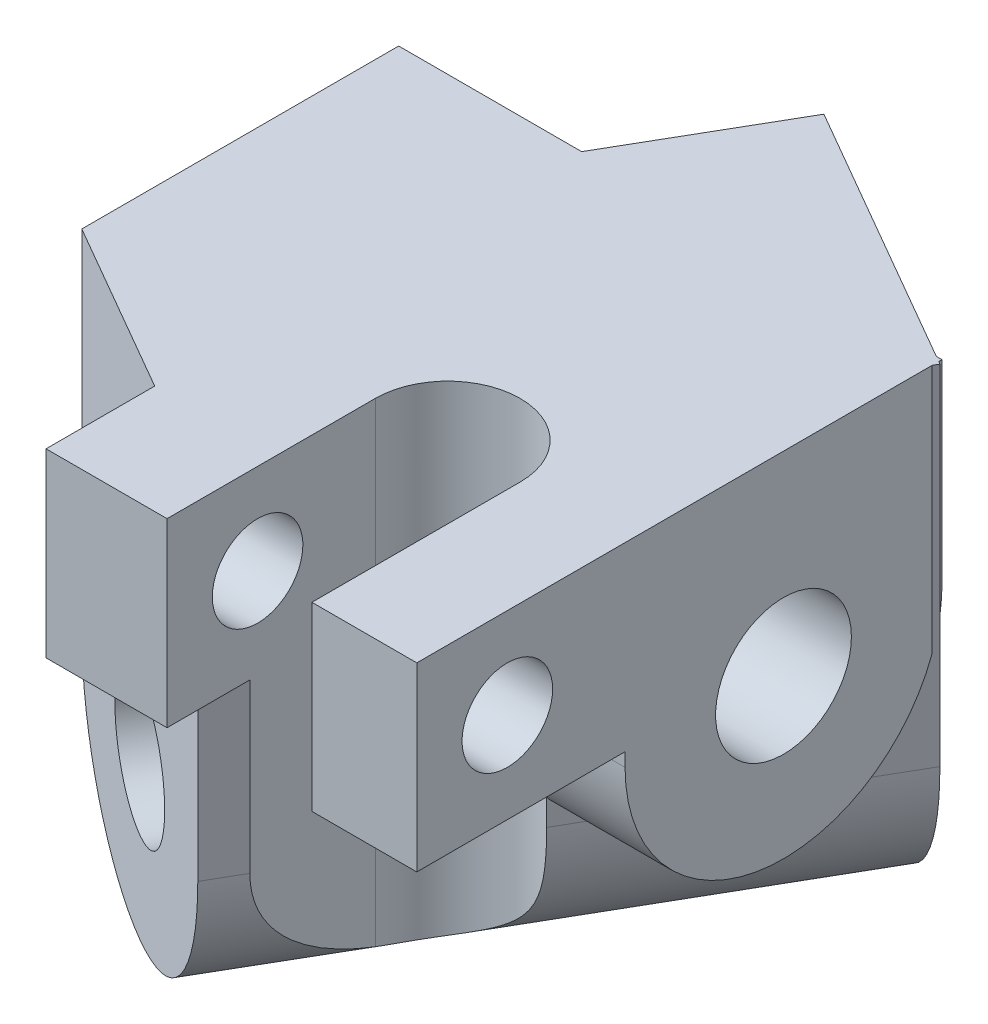
from build123d import *

# Parameters (mm, degrees)
SKETCH1_R           = 3.75
BOSS_EXTRUDE1_DEPTH = 30
SKETCH2_R           = 3.75
BOSS_EXTRUDE2_DEPTH = 30
CUT_EXTRUDE1_DEPTH  = 29.0000001
SKETCH4_W           = 5.792740578
SKETCH4_H           = 11.5
BOSS_EXTRUDE3_DEPTH = 10
BOSS_EXTRUDE4_DEPTH = 10
SKETCH5_R           = 2.5
CUT_EXTRUDE2_DEPTH  = 31.0000001
SKETCH7_R           = 3.75
CUT_EXTRUDE3_DEPTH  = 31.155444666
SKETCH8_R           = 3.75
CUT_EXTRUDE4_DEPTH  = 38.57772242


with BuildPart() as part:
    # Sketch1 → Boss-Extrude1 (new body)
    with BuildSketch(Plane(origin=(0, 0, 0), x_dir=(0, 0, -1), z_dir=(1, 0, 0))):
        with BuildLine():
            Line((-8.75, 0), (8.75, 0))
            Line((8.75, 0), (8.75, 10.75))
            ThreePointArc((8.75, 10.75), (0, 19.5), (-8.75, 10.75))
            Line((-8.75, 10.75), (-8.75, 0))
        make_face()
        with Locations((0, 10.75)):
            Circle(SKETCH1_R, mode=Mode.SUBTRACT)
    extrude(amount=BOSS_EXTRUDE1_DEPTH)

    # Sketch2 → Boss-Extrude2 (add)
    with BuildSketch(Plane(origin=(-3.788861142, 0, 6.5625), x_dir=(-0.866025404, 0, -0.5), z_dir=(0.5, 0, -0.866025404))):
        with BuildLine():
            Line((-4.375, 0), (-4.375, 19.25))
            ThreePointArc((-4.375, 19.25), (-13.125, 28), (-21.875, 19.25))
            Line((-21.875, 19.25), (-21.875, 0))
            Line((-21.875, 0), (-4.375, 0))
        make_face()
        with Locations((-13.125, 19.25)):
            Circle(SKETCH2_R, mode=Mode.SUBTRACT)
    extrude(amount=BOSS_EXTRUDE2_DEPTH)

    # Sketch3 → Cut-Extrude1 (cut, through all)
    with BuildSketch(Plane.XZ):
        with BuildLine():
            Line((24.207259422, 8.75), (24.207259422, 15.67820323))
            Line((24.207259422, 15.67820323), (16.207259422, 15.67820323))
            Line((16.207259422, 15.67820323), (16.207259422, 8.75))
            ThreePointArc((16.207259422, 8.75), (20.207259422, 4.75), (24.207259422, 8.75))
        make_face()
    extrude(amount=-CUT_EXTRUDE1_DEPTH, mode=Mode.SUBTRACT)

    # Sketch4 → Boss-Extrude3 (add)
    with BuildSketch(Plane.XZ):
        with Locations((27.103629711, 14.5)):
            Rectangle(SKETCH4_W, SKETCH4_H)
    extrude(amount=-BOSS_EXTRUDE3_DEPTH)

    # Sketch6 → Boss-Extrude4 (add)
    with BuildSketch(Plane.XZ):
        Polygon((16.207259422, 15.67820323), (16.207259422, 20.25), (9.526279442, 20.25), (9.526279442, 14.25), align=None)
    extrude(amount=-BOSS_EXTRUDE4_DEPTH)

    # Sketch5 → Cut-Extrude2 (cut, through all)
    with BuildSketch(Plane(origin=(30, 0, 0), x_dir=(0, 0, -1), z_dir=(1, 0, 0))):
        with Locations(Location((-15.25, 5, 0), (0, 0, 66.421821522))):  # turned: the seam where the file's is
            Circle(SKETCH5_R)
    extrude(amount=-CUT_EXTRUDE2_DEPTH, mode=Mode.SUBTRACT)

    # Sketch7 → Cut-Extrude3 (cut, through all)
    with BuildSketch(Plane.ZY):
        with Locations(Location((0, 10.75, 0), (0, 0, 180))):  # turned: the seam where the file's is
            Circle(SKETCH7_R)
    extrude(amount=-CUT_EXTRUDE3_DEPTH, mode=Mode.SUBTRACT)

    # Sketch8 → Cut-Extrude4 (cut, through all)
    with BuildSketch(Plane(origin=(-3.788861142, 0, 6.5625), x_dir=(0.866025404, 0, 0.5), z_dir=(-0.5, 0, 0.866025404))):
        with Locations(Location((13.125, 19.25, 0), (0, 0, 180))):  # turned: the seam where the file's is
            Circle(SKETCH8_R)
    extrude(amount=-CUT_EXTRUDE4_DEPTH, mode=Mode.SUBTRACT)


with BuildPart() as body_2:
    # Mirror1: mirrored copy
    add(part.part.mirror(Plane(origin=(30, 0, 8.75), x_dir=(0, 0, 1), z_dir=(0, 1, 0))))


solid = body_2.part
